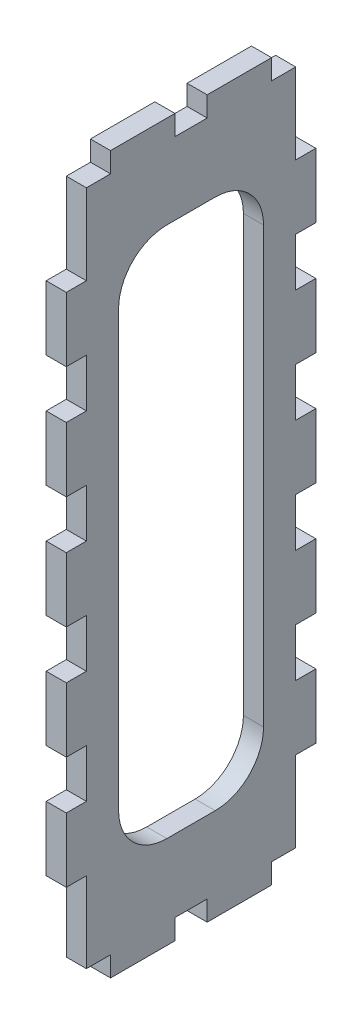
from build123d import *

# Parameters (mm, degrees)
SKETCH1_W               = 33.02
SKETCH1_H               = 106.68
BOSS_EXTRUDE1_DEPTH     = 3.175
SKETCH3_W               = 3.175
SKETCH3_H               = 10.16
BOSS_EXTRUDE2_DEPTH     = 3.175
LPATTERN1_COUNT         = 5
LPATTERN1_PITCH         = 17.78
MIRROR1_COPY_1_SKETCH_W = 3.175
MIRROR1_COPY_1_SKETCH_H = 10.16
MIRROR1_COPY_1_DEPTH    = 3.175
MIRROR1_COPY_2_SKETCH_W = 3.175
MIRROR1_COPY_2_SKETCH_H = 10.16
MIRROR1_COPY_2_DEPTH    = 3.175
MIRROR1_COPY_3_SKETCH_W = 3.175
MIRROR1_COPY_3_SKETCH_H = 10.16
MIRROR1_COPY_3_DEPTH    = 3.175
MIRROR1_COPY_4_SKETCH_W = 3.175
MIRROR1_COPY_4_SKETCH_H = 10.16
MIRROR1_COPY_4_DEPTH    = 3.175
SKETCH4_W               = 3.175
SKETCH4_H               = 10.16
BOSS_EXTRUDE3_DEPTH     = 3.175
MIRROR3_COPY_1_SKETCH_W = 3.175
MIRROR3_COPY_1_SKETCH_H = 10.16
MIRROR3_COPY_1_DEPTH    = 3.175


with BuildPart() as part:
    # Sketch1 → Boss-Extrude1 (new body)
    with BuildSketch(Plane(origin=(0, 0, 0), x_dir=(0, 0, -1), z_dir=(1, 0, 0))):
        with Locations((0.241329403, -2.63343568)):
            Rectangle(SKETCH1_W, SKETCH1_H)
        with BuildLine():
            Line((4.051329403, 39.27656432), (-3.568670597, 39.27656432))
            ThreePointArc((-3.568670597, 39.27656432), (-8.95682427, 37.044717993), (-11.188670597, 31.65656432))
            Line((-11.188670597, 31.65656432), (-11.188670597, -36.92343568))
            ThreePointArc((-11.188670597, -36.92343568), (-8.95682427, -42.311589352), (-3.568670597, -44.54343568))
            Line((-3.568670597, -44.54343568), (4.051329403, -44.54343568))
            ThreePointArc((4.051329403, -44.54343568), (9.439483075, -42.311589352), (11.671329403, -36.92343568))
            Line((11.671329403, -36.92343568), (11.671329403, 31.65656432))
            ThreePointArc((11.671329403, 31.65656432), (9.439483075, 37.044717993), (4.051329403, 39.27656432))
        make_face(mode=Mode.SUBTRACT)
    extrude(amount=BOSS_EXTRUDE1_DEPTH)

    # Sketch3 → Boss-Extrude2 (add)
    with BuildSketch(Plane.XY.offset(16.268670597)):
        with Locations((1.5875, 32.92656432)):
            Rectangle(SKETCH3_W, SKETCH3_H)
    boss_extrude2 = extrude(amount=BOSS_EXTRUDE2_DEPTH)

    # LPattern1: Boss-Extrude2 ×5
    with Locations(*[(0, -i * LPATTERN1_PITCH, 0) for i in range(1, LPATTERN1_COUNT)]):
        add(boss_extrude2)

    # Mirror1: Boss-Extrude2 across plane
    add(boss_extrude2.mirror(Plane(origin=(0, 0, -0.241329403), x_dir=(1, 0, 0), z_dir=(0, 0, -1))))

    # Mirror1 copy 1 sketch → Mirror1 copy 1 (add)
    with BuildSketch(Plane(origin=(0, -17.78, -16.751329403), x_dir=(1, 0, 0), z_dir=(0, 0, -1))):
        with Locations((1.5875, -32.92656432)):
            Rectangle(MIRROR1_COPY_1_SKETCH_W, MIRROR1_COPY_1_SKETCH_H)
    extrude(amount=MIRROR1_COPY_1_DEPTH)

    # Mirror1 copy 2 sketch → Mirror1 copy 2 (add)
    with BuildSketch(Plane(origin=(0, -35.56, -16.751329403), x_dir=(1, 0, 0), z_dir=(0, 0, -1))):
        with Locations((1.5875, -32.92656432)):
            Rectangle(MIRROR1_COPY_2_SKETCH_W, MIRROR1_COPY_2_SKETCH_H)
    extrude(amount=MIRROR1_COPY_2_DEPTH)

    # Mirror1 copy 3 sketch → Mirror1 copy 3 (add)
    with BuildSketch(Plane(origin=(0, -53.34, -16.751329403), x_dir=(1, 0, 0), z_dir=(0, 0, -1))):
        with Locations((1.5875, -32.92656432)):
            Rectangle(MIRROR1_COPY_3_SKETCH_W, MIRROR1_COPY_3_SKETCH_H)
    extrude(amount=MIRROR1_COPY_3_DEPTH)

    # Mirror1 copy 4 sketch → Mirror1 copy 4 (add)
    with BuildSketch(Plane(origin=(0, -71.12, -16.751329403), x_dir=(1, 0, 0), z_dir=(0, 0, -1))):
        with Locations((1.5875, -32.92656432)):
            Rectangle(MIRROR1_COPY_4_SKETCH_W, MIRROR1_COPY_4_SKETCH_H)
    extrude(amount=MIRROR1_COPY_4_DEPTH)

    # Sketch4 → Boss-Extrude3 (add)
    with BuildSketch(Plane(origin=(0, 50.70656432, 0), x_dir=(1, 0, 0), z_dir=(0, 1, 0))):
        with Locations((1.5875, -7.378670597)):
            Rectangle(SKETCH4_W, SKETCH4_H)
    boss_extrude3 = extrude(amount=BOSS_EXTRUDE3_DEPTH)

    # Mirror2: Boss-Extrude3 across plane
    add(boss_extrude3.mirror(Plane(origin=(0, 0, -0.241329403), x_dir=(1, 0, 0), z_dir=(0, 0, -1))))

    # Mirror3: Boss-Extrude3 across plane
    add(boss_extrude3.mirror(Plane.ZX.offset(-2.63343568)))

    # Mirror3 copy 1 sketch → Mirror3 copy 1 (add)
    with BuildSketch(Plane(origin=(0, -55.97343568, -0.482658805), x_dir=(1, 0, 0), z_dir=(0, -1, 0))):
        with Locations((1.5875, -7.378670597)):
            Rectangle(MIRROR3_COPY_1_SKETCH_W, MIRROR3_COPY_1_SKETCH_H)
    extrude(amount=MIRROR3_COPY_1_DEPTH)


solid = part.part
